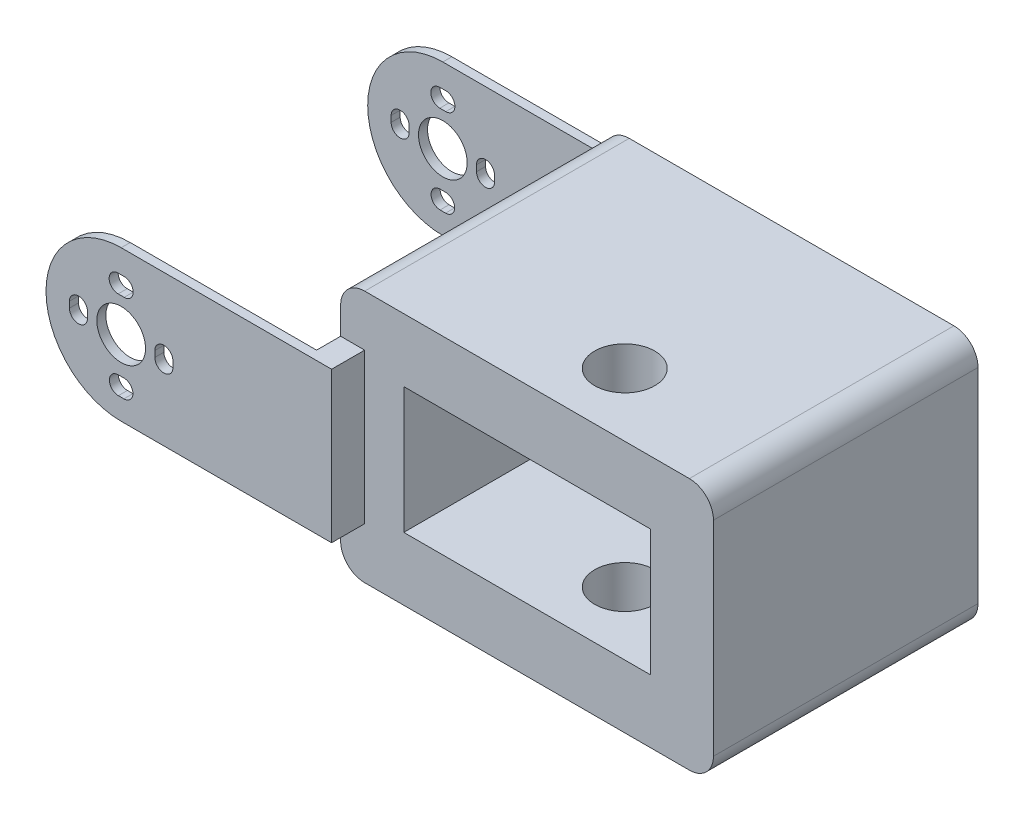
from build123d import *

# Parameters (mm, degrees)
SKETCH1_W           = 62
SKETCH1_H           = 42
SKETCH1_W_2         = 41
SKETCH1_H_2         = 21
BOSS_EXTRUDE1_DEPTH = 43
SKETCH2_W           = 4
SKETCH2_H           = 25
BOSS_EXTRUDE2_DEPTH = 4
SKETCH3_W           = 4
SKETCH3_H           = 25
BOSS_EXTRUDE6_DEPTH = 1.5
SKETCH3_8_W         = 4
SKETCH3_8_H         = 25
BOSS_EXTRUDE7_DEPTH = 53.5
CUT_EXTRUDE1_DEPTH  = 52
SKETCH_1_R          = 5
CUT_EXTRUDE_1_DEPTH = 42
EXTRUDE_1_DEPTH     = 1
SKETCH_2_3_R        = 7
EXTRUDE_2_DEPTH     = 1
FILLET_1_R          = 4
FILLET_2_R          = 4
FILLET_3_R          = 4
FILLET_4_R          = 4


with BuildPart() as part:
    # Sketch1 → Boss-Extrude1 (new body)
    with BuildSketch(Plane.XY):
        with Locations((1.904162196, -4.136072895)):
            Rectangle(SKETCH1_W, SKETCH1_H)
        with Locations((1.904162196, -4.136072895)):
            Rectangle(SKETCH1_W_2, SKETCH1_H_2, mode=Mode.SUBTRACT)
    extrude(amount=BOSS_EXTRUDE1_DEPTH)

    # Sketch2 → Boss-Extrude2 (add)
    with BuildSketch(Plane.XY.offset(43)):
        with Locations((-27.095837804, -4.136072895)):
            Rectangle(SKETCH2_W, SKETCH2_H)
    extrude(amount=BOSS_EXTRUDE2_DEPTH)

    # Sketch3 → Boss-Extrude6 (add)
    with BuildSketch(Plane.XY.offset(47)):
        with BuildLine():
            Line((-60.095837804, 4.463927105), (-60.095837804, 8.363927105))
            ThreePointArc((-60.095837804, 8.363927105), (-72.595837804, -4.136072895), (-60.095837804, -16.636072895))
            Line((-60.095837804, -16.636072895), (-60.095837804, -13.176248856))
            Line((-60.095837804, -13.176248856), (-60.555926168, -13.176248856))
            ThreePointArc((-60.555926168, -13.176248856), (-62.055926168, -11.676248856), (-60.555926168, -10.176248856))
            Line((-60.555926168, -10.176248856), (-60.095837804, -10.176248856))
            Line((-60.095837804, -10.176248856), (-60.095837804, -8.186072895))
            ThreePointArc((-60.095837804, -8.186072895), (-64.145837804, -4.136072895), (-60.095837804, -0.086072895))
            Line((-60.095837804, -0.086072895), (-60.095837804, 1.463927105))
            Line((-60.095837804, 1.463927105), (-60.595837804, 1.463927105))
            ThreePointArc((-60.595837804, 1.463927105), (-62.095837804, 2.963927105), (-60.595837804, 4.463927105))
            Line((-60.595837804, 4.463927105), (-60.095837804, 4.463927105))
        make_face()
        with BuildLine():
            ThreePointArc((-68.695837804, -3.636072895), (-67.195837804, -2.136072895), (-65.695837804, -3.636072895))
            Line((-65.695837804, -3.636072895), (-65.695837804, -4.636072895))
            ThreePointArc((-65.695837804, -4.636072895), (-67.195837804, -6.136072895), (-68.695837804, -4.636072895))
            Line((-68.695837804, -4.636072895), (-68.695837804, -3.636072895))
        make_face(mode=Mode.SUBTRACT)
        with BuildLine():
            Line((-29.095837804, -16.636072895), (-29.095837804, 8.363927105))
            Line((-29.095837804, 8.363927105), (-60.095837804, 8.363927105))
            Line((-60.095837804, 8.363927105), (-60.095837804, 4.463927105))
            Line((-60.095837804, 4.463927105), (-59.595837804, 4.463927105))
            ThreePointArc((-59.595837804, 4.463927105), (-58.095837804, 2.963927105), (-59.595837804, 1.463927105))
            Line((-59.595837804, 1.463927105), (-60.095837804, 1.463927105))
            Line((-60.095837804, 1.463927105), (-60.095837804, -0.086072895))
            ThreePointArc((-60.095837804, -0.086072895), (-57.23205534, -1.272290432), (-56.045837804, -4.136072895))
            ThreePointArc((-56.045837804, -4.136072895), (-57.23205534, -6.999855359), (-60.095837804, -8.186072895))
            Line((-60.095837804, -8.186072895), (-60.095837804, -10.176248856))
            Line((-60.095837804, -10.176248856), (-59.635749439, -10.176248856))
            ThreePointArc((-59.635749439, -10.176248856), (-58.135749439, -11.676248856), (-59.635749439, -13.176248856))
            Line((-59.635749439, -13.176248856), (-60.095837804, -13.176248856))
            Line((-60.095837804, -13.176248856), (-60.095837804, -16.636072895))
            Line((-60.095837804, -16.636072895), (-29.095837804, -16.636072895))
        make_face()
        with BuildLine():
            ThreePointArc((-54.495837804, -3.636072895), (-52.995837804, -2.136072895), (-51.495837804, -3.636072895))
            Line((-51.495837804, -3.636072895), (-51.495837804, -4.636072895))
            ThreePointArc((-51.495837804, -4.636072895), (-52.995837804, -6.136072895), (-54.495837804, -4.636072895))
            Line((-54.495837804, -4.636072895), (-54.495837804, -3.636072895))
        make_face(mode=Mode.SUBTRACT)
        with Locations((-27.095837804, -4.136072895)):
            Rectangle(SKETCH3_W, SKETCH3_H)
    extrude(amount=BOSS_EXTRUDE6_DEPTH)

    # Sketch3_8 → Boss-Extrude7 (add)
    with BuildSketch(Plane.XY.offset(47)):
        with BuildLine():
            Line((-60.095837804, 4.463927105), (-60.095837804, 8.363927105))
            ThreePointArc((-60.095837804, 8.363927105), (-72.595837804, -4.136072895), (-60.095837804, -16.636072895))
            Line((-60.095837804, -16.636072895), (-60.095837804, -13.176248856))
            Line((-60.095837804, -13.176248856), (-60.555926168, -13.176248856))
            ThreePointArc((-60.555926168, -13.176248856), (-62.055926168, -11.676248856), (-60.555926168, -10.176248856))
            Line((-60.555926168, -10.176248856), (-60.095837804, -10.176248856))
            Line((-60.095837804, -10.176248856), (-60.095837804, -8.186072895))
            ThreePointArc((-60.095837804, -8.186072895), (-64.145837804, -4.136072895), (-60.095837804, -0.086072895))
            Line((-60.095837804, -0.086072895), (-60.095837804, 1.463927105))
            Line((-60.095837804, 1.463927105), (-60.595837804, 1.463927105))
            ThreePointArc((-60.595837804, 1.463927105), (-62.095837804, 2.963927105), (-60.595837804, 4.463927105))
            Line((-60.595837804, 4.463927105), (-60.095837804, 4.463927105))
        make_face()
        with BuildLine():
            ThreePointArc((-68.695837804, -3.636072895), (-67.195837804, -2.136072895), (-65.695837804, -3.636072895))
            Line((-65.695837804, -3.636072895), (-65.695837804, -4.636072895))
            ThreePointArc((-65.695837804, -4.636072895), (-67.195837804, -6.136072895), (-68.695837804, -4.636072895))
            Line((-68.695837804, -4.636072895), (-68.695837804, -3.636072895))
        make_face(mode=Mode.SUBTRACT)
        with BuildLine():
            Line((-29.095837804, -16.636072895), (-29.095837804, 8.363927105))
            Line((-29.095837804, 8.363927105), (-60.095837804, 8.363927105))
            Line((-60.095837804, 8.363927105), (-60.095837804, 4.463927105))
            Line((-60.095837804, 4.463927105), (-59.595837804, 4.463927105))
            ThreePointArc((-59.595837804, 4.463927105), (-58.095837804, 2.963927105), (-59.595837804, 1.463927105))
            Line((-59.595837804, 1.463927105), (-60.095837804, 1.463927105))
            Line((-60.095837804, 1.463927105), (-60.095837804, -0.086072895))
            ThreePointArc((-60.095837804, -0.086072895), (-57.23205534, -1.272290432), (-56.045837804, -4.136072895))
            ThreePointArc((-56.045837804, -4.136072895), (-57.23205534, -6.999855359), (-60.095837804, -8.186072895))
            Line((-60.095837804, -8.186072895), (-60.095837804, -10.176248856))
            Line((-60.095837804, -10.176248856), (-59.635749439, -10.176248856))
            ThreePointArc((-59.635749439, -10.176248856), (-58.135749439, -11.676248856), (-59.635749439, -13.176248856))
            Line((-59.635749439, -13.176248856), (-60.095837804, -13.176248856))
            Line((-60.095837804, -13.176248856), (-60.095837804, -16.636072895))
            Line((-60.095837804, -16.636072895), (-29.095837804, -16.636072895))
        make_face()
        with BuildLine():
            ThreePointArc((-54.495837804, -3.636072895), (-52.995837804, -2.136072895), (-51.495837804, -3.636072895))
            Line((-51.495837804, -3.636072895), (-51.495837804, -4.636072895))
            ThreePointArc((-51.495837804, -4.636072895), (-52.995837804, -6.136072895), (-54.495837804, -4.636072895))
            Line((-54.495837804, -4.636072895), (-54.495837804, -3.636072895))
        make_face(mode=Mode.SUBTRACT)
        with Locations((-27.095837804, -4.136072895)):
            Rectangle(SKETCH3_8_W, SKETCH3_8_H)
    extrude(amount=-BOSS_EXTRUDE7_DEPTH)

    # Sketch3_11 → Cut-Extrude1 (cut)
    with BuildSketch(Plane.XY.offset(47)):
        with BuildLine():
            Line((-29.095837804, -16.636072895), (-29.095837804, 8.363927105))
            Line((-29.095837804, 8.363927105), (-60.095837804, 8.363927105))
            Line((-60.095837804, 8.363927105), (-60.095837804, 4.463927105))
            Line((-60.095837804, 4.463927105), (-59.595837804, 4.463927105))
            ThreePointArc((-59.595837804, 4.463927105), (-58.095837804, 2.963927105), (-59.595837804, 1.463927105))
            Line((-59.595837804, 1.463927105), (-60.095837804, 1.463927105))
            Line((-60.095837804, 1.463927105), (-60.095837804, -0.086072895))
            ThreePointArc((-60.095837804, -0.086072895), (-57.23205534, -1.272290432), (-56.045837804, -4.136072895))
            ThreePointArc((-56.045837804, -4.136072895), (-57.23205534, -6.999855359), (-60.095837804, -8.186072895))
            Line((-60.095837804, -8.186072895), (-60.095837804, -10.176248856))
            Line((-60.095837804, -10.176248856), (-59.635749439, -10.176248856))
            ThreePointArc((-59.635749439, -10.176248856), (-58.135749439, -11.676248856), (-59.635749439, -13.176248856))
            Line((-59.635749439, -13.176248856), (-60.095837804, -13.176248856))
            Line((-60.095837804, -13.176248856), (-60.095837804, -16.636072895))
            Line((-60.095837804, -16.636072895), (-29.095837804, -16.636072895))
        make_face()
        with BuildLine():
            ThreePointArc((-54.495837804, -3.636072895), (-52.995837804, -2.136072895), (-51.495837804, -3.636072895))
            Line((-51.495837804, -3.636072895), (-51.495837804, -4.636072895))
            ThreePointArc((-51.495837804, -4.636072895), (-52.995837804, -6.136072895), (-54.495837804, -4.636072895))
            Line((-54.495837804, -4.636072895), (-54.495837804, -3.636072895))
        make_face(mode=Mode.SUBTRACT)
        with BuildLine():
            Line((-60.095837804, 4.463927105), (-60.095837804, 8.363927105))
            ThreePointArc((-60.095837804, 8.363927105), (-72.595837804, -4.136072895), (-60.095837804, -16.636072895))
            Line((-60.095837804, -16.636072895), (-60.095837804, -13.176248856))
            Line((-60.095837804, -13.176248856), (-60.555926168, -13.176248856))
            ThreePointArc((-60.555926168, -13.176248856), (-62.055926168, -11.676248856), (-60.555926168, -10.176248856))
            Line((-60.555926168, -10.176248856), (-60.095837804, -10.176248856))
            Line((-60.095837804, -10.176248856), (-60.095837804, -8.186072895))
            ThreePointArc((-60.095837804, -8.186072895), (-64.145837804, -4.136072895), (-60.095837804, -0.086072895))
            Line((-60.095837804, -0.086072895), (-60.095837804, 1.463927105))
            Line((-60.095837804, 1.463927105), (-60.595837804, 1.463927105))
            ThreePointArc((-60.595837804, 1.463927105), (-62.095837804, 2.963927105), (-60.595837804, 4.463927105))
            Line((-60.595837804, 4.463927105), (-60.095837804, 4.463927105))
        make_face()
        with BuildLine():
            ThreePointArc((-68.695837804, -3.636072895), (-67.195837804, -2.136072895), (-65.695837804, -3.636072895))
            Line((-65.695837804, -3.636072895), (-65.695837804, -4.636072895))
            ThreePointArc((-65.695837804, -4.636072895), (-67.195837804, -6.136072895), (-68.695837804, -4.636072895))
            Line((-68.695837804, -4.636072895), (-68.695837804, -3.636072895))
        make_face(mode=Mode.SUBTRACT)
    extrude(amount=-CUT_EXTRUDE1_DEPTH, mode=Mode.SUBTRACT)

    # 草圖1 → 除料-伸長1 (cut)
    with BuildSketch(Plane(origin=(0, 16.863927105, 0), x_dir=(1, 0, 0), z_dir=(0, 1, 0))):
        with Locations(Location((7.653776732, -32.500385465, 0), (0, 0, 180))):
            Circle(SKETCH_1_R)
    extrude(amount=-CUT_EXTRUDE_1_DEPTH, mode=Mode.SUBTRACT)

    # 草圖2 → 填料-伸長1 (add)
    with BuildSketch(Plane(origin=(0, 0, 0), x_dir=(-1, 0, 0), z_dir=(0, 0, -1))):
        with BuildLine():
            Line((-22.404162196, 6.363927105), (-22.404162196, -4.136072895))
            Line((-22.404162196, -4.136072895), (-19.404162196, -4.136072895))
            ThreePointArc((-19.404162196, -4.136072895), (-12.404162196, 2.863927105), (-5.404162196, -4.136072895))
            Line((-5.404162196, -4.136072895), (18.595837804, -4.136072895))
            Line((18.595837804, -4.136072895), (18.595837804, 6.363927105))
            Line((18.595837804, 6.363927105), (-22.404162196, 6.363927105))
        make_face()
        with BuildLine():
            Line((-22.404162196, -4.136072895), (-22.404162196, -14.636072895))
            Line((-22.404162196, -14.636072895), (18.595837804, -14.636072895))
            Line((18.595837804, -14.636072895), (18.595837804, -4.136072895))
            Line((18.595837804, -4.136072895), (-5.404162196, -4.136072895))
            ThreePointArc((-5.404162196, -4.136072895), (-12.404162196, -11.136072895), (-19.404162196, -4.136072895))
            Line((-19.404162196, -4.136072895), (-22.404162196, -4.136072895))
        make_face()
    extrude(amount=-EXTRUDE_1_DEPTH)

    # 草圖2<3> → 填料-伸長2 (add)
    with BuildSketch(Plane(origin=(0, 0, 0), x_dir=(-1, 0, 0), z_dir=(0, 0, -1))):
        Polygon((29.095837804, 8.363927105), (29.095837804, 16.863927105), (-32.904162196, 16.863927105), (-32.904162196, -25.136072895), (29.095837804, -25.136072895), (29.095837804, -16.636072895), (25.095837804, -16.636072895), (25.095837804, 8.363927105), align=None)
        with Locations((-12.404162196, -4.136072895)):
            Circle(SKETCH_2_3_R, mode=Mode.SUBTRACT)
    extrude(amount=EXTRUDE_2_DEPTH)

    # 圓角1
    fillet_1_edges = [part.edges().sort_by_distance(p)[0] for p in [
        (32.904162196, -25.136072895, 21),
    ]]
    fillet(fillet_1_edges, radius=FILLET_1_R)

    # 圓角2
    fillet_2_edges = [part.edges().sort_by_distance(p)[0] for p in [
        (-29.095837804, -25.136072895, 21),
    ]]
    fillet(fillet_2_edges, radius=FILLET_2_R)

    # 圓角3
    fillet_3_edges = [part.edges().sort_by_distance(p)[0] for p in [
        (32.904162196, 16.863927105, 21),
    ]]
    fillet(fillet_3_edges, radius=FILLET_3_R)

    # 圓角4
    fillet_4_edges = [part.edges().sort_by_distance(p)[0] for p in [
        (-29.095837804, 16.863927105, 21),
    ]]
    fillet(fillet_4_edges, radius=FILLET_4_R)


solid = part.part
